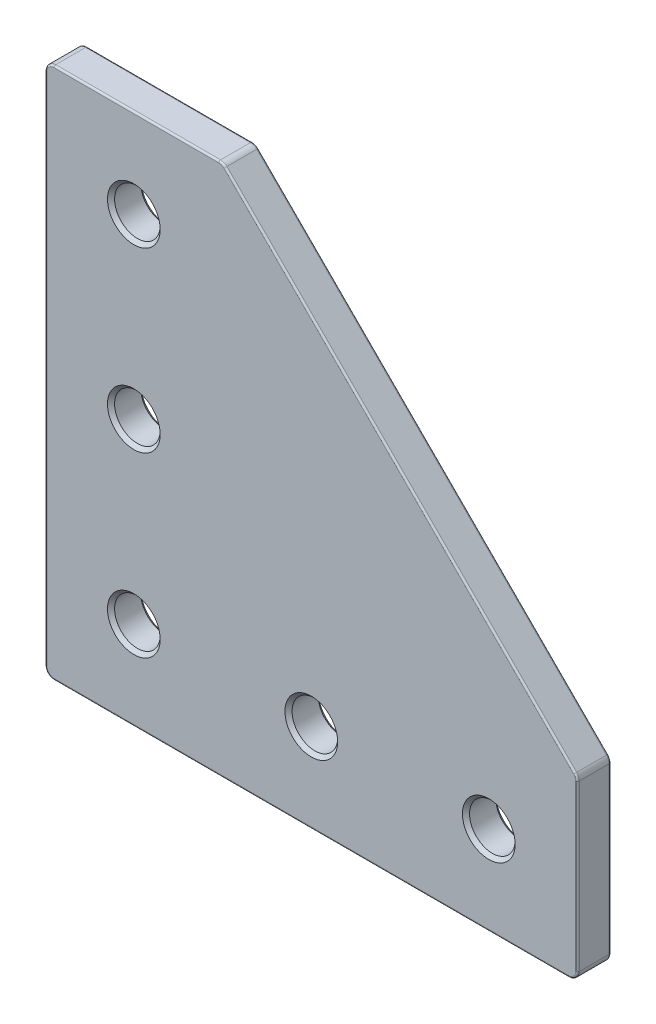
from build123d import *

# Parameters (mm, degrees)
BOSS_EXTRUDE1_START         = -2.3876
BOSS_EXTRUDE1_DEPTH         = 4.7752
SKETCH4_R                   = 3.2639
CUT_EXTRUDE1_DEPTH          = 55.092721646
LPATTERN1_COUNT             = 3
LPATTERN1_PITCH             = 25.4
CIRPATTERN1_COPY_1_SKETCH_R = 3.2639
CIRPATTERN1_COPY_1_DEPTH    = 55.092721646
CIRPATTERN1_COPY_2_SKETCH_R = 3.2639
CIRPATTERN1_COPY_2_DEPTH    = 55.092721646
CIRPATTERN1_COPY_7_SKETCH_R = 3.2639
CIRPATTERN1_COPY_7_DEPTH    = 55.092721646
FILLET1_R                   = 1.27
FILLET2_R                   = 0.254


with BuildPart() as part:
    # Sketch3 → Boss-Extrude1 (new body)
    with BuildSketch(Plane.XY.offset(BOSS_EXTRUDE1_START)):
        Polygon((-38.1, 38.1), (-38.1, -38.1), (38.1, -38.1), (38.1, -12.7), (-12.7, 38.1), align=None)
    extrude(amount=BOSS_EXTRUDE1_DEPTH)

    # Sketch4 → Cut-Extrude1 (cut, symmetric)
    with BuildSketch(Plane.XY.offset(2.3876)):
        with Locations((-25.4, -25.4)):
            Circle(SKETCH4_R)
    cut_extrude1 = extrude(amount=CUT_EXTRUDE1_DEPTH, both=True, mode=Mode.SUBTRACT)

    # Cut-Extrude2 cone 1 section (through the dimple's axis) → Cut-Extrude2 (revolve, cut)
    with BuildSketch(Plane(origin=(-25.4, -25.4, 2.3876), x_dir=(0, -1, 0), z_dir=(1, 0, 0))):
        Polygon((0, 0), (3.7719, 0), (0, 3.7719), align=None)
    cut_extrude2 = revolve(axis=Axis((-25.4, -25.4, 2.3876), (0, 0, -1)), mode=Mode.SUBTRACT)

    # Cut-Extrude3 cone 1 section (through the dimple's axis) → Cut-Extrude3 (revolve, cut)
    with BuildSketch(Plane(origin=(-25.4, -25.4, -2.3876), x_dir=(0, 1, 0), z_dir=(1, 0, 0))):
        Polygon((0, 0), (3.7719, 0), (0, 3.7719), align=None)
    cut_extrude3 = revolve(axis=Axis((-25.4, -25.4, -2.3876), (0, 0, 1)), mode=Mode.SUBTRACT)

    # LPattern1: Cut-Extrude1, Cut-Extrude2, Cut-Extrude3 ×3
    with Locations(*[(0, i * LPATTERN1_PITCH, 0) for i in range(1, LPATTERN1_COUNT)]):
        add(cut_extrude1, mode=Mode.SUBTRACT)
        add(cut_extrude2, mode=Mode.SUBTRACT)
        add(cut_extrude3, mode=Mode.SUBTRACT)

    # CirPattern1 copy 1 sketch → CirPattern1 copy 1 (cut, symmetric)
    with BuildSketch(Plane(origin=(25.4, -50.8, 2.3876), x_dir=(0, -1, 0), z_dir=(0, 0, 1))):
        with Locations((-25.4, -25.4)):
            Circle(CIRPATTERN1_COPY_1_SKETCH_R)
    extrude(amount=CIRPATTERN1_COPY_1_DEPTH, both=True, mode=Mode.SUBTRACT)

    # CirPattern1 copy 2 sketch → CirPattern1 copy 2 (cut, symmetric)
    with BuildSketch(Plane(origin=(50.8, -50.8, 2.3876), x_dir=(0, -1, 0), z_dir=(0, 0, 1))):
        with Locations((-25.4, -25.4)):
            Circle(CIRPATTERN1_COPY_2_SKETCH_R)
    extrude(amount=CIRPATTERN1_COPY_2_DEPTH, both=True, mode=Mode.SUBTRACT)

    # CirPattern1 copy 3 sketch → CirPattern1 copy 3 (revolve, cut)
    with BuildSketch(Plane(origin=(0, -25.4, 2.3876), x_dir=(-1, 0, 0), z_dir=(0, -1, 0))):
        Polygon((0, 0), (3.7719, 0), (0, 3.7719), align=None)
    revolve(axis=Axis((0, -25.4, 2.3876), (0, 0, -1)), mode=Mode.SUBTRACT)

    # CirPattern1 copy 4 sketch → CirPattern1 copy 4 (revolve, cut)
    with BuildSketch(Plane(origin=(25.4, -25.4, 2.3876), x_dir=(-1, 0, 0), z_dir=(0, -1, 0))):
        Polygon((0, 0), (3.7719, 0), (0, 3.7719), align=None)
    revolve(axis=Axis((25.4, -25.4, 2.3876), (0, 0, -1)), mode=Mode.SUBTRACT)

    # CirPattern1 copy 5 sketch → CirPattern1 copy 5 (revolve, cut)
    with BuildSketch(Plane(origin=(0, -25.4, -2.3876), x_dir=(1, 0, 0), z_dir=(0, -1, 0))):
        Polygon((0, 0), (3.7719, 0), (0, 3.7719), align=None)
    revolve(axis=Axis((0, -25.4, -2.3876), (0, 0, 1)), mode=Mode.SUBTRACT)

    # CirPattern1 copy 6 sketch → CirPattern1 copy 6 (revolve, cut)
    with BuildSketch(Plane(origin=(25.4, -25.4, -2.3876), x_dir=(1, 0, 0), z_dir=(0, -1, 0))):
        Polygon((0, 0), (3.7719, 0), (0, 3.7719), align=None)
    revolve(axis=Axis((25.4, -25.4, -2.3876), (0, 0, 1)), mode=Mode.SUBTRACT)

    # CirPattern1 copy 7 sketch → CirPattern1 copy 7 (cut, symmetric)
    with BuildSketch(Plane(origin=(0, -50.8, 2.3876), x_dir=(0, -1, 0), z_dir=(0, 0, 1))):
        with Locations((-25.4, -25.4)):
            Circle(CIRPATTERN1_COPY_7_SKETCH_R)
    extrude(amount=CIRPATTERN1_COPY_7_DEPTH, both=True, mode=Mode.SUBTRACT)

    # CirPattern1 copy 8 sketch → CirPattern1 copy 8 (revolve, cut)
    with BuildSketch(Plane(origin=(-25.4, -25.4, 2.3876), x_dir=(-1, 0, 0), z_dir=(0, -1, 0))):
        Polygon((0, 0), (3.7719, 0), (0, 3.7719), align=None)
    revolve(axis=Axis((-25.4, -25.4, 2.3876), (0, 0, -1)), mode=Mode.SUBTRACT)

    # CirPattern1 copy 9 sketch → CirPattern1 copy 9 (revolve, cut)
    with BuildSketch(Plane(origin=(-25.4, -25.4, -2.3876), x_dir=(1, 0, 0), z_dir=(0, -1, 0))):
        Polygon((0, 0), (3.7719, 0), (0, 3.7719), align=None)
    revolve(axis=Axis((-25.4, -25.4, -2.3876), (0, 0, 1)), mode=Mode.SUBTRACT)

    # Fillet1
    fillet1_edges = [part.edges().sort_by_distance(p)[0] for p in [
        (-12.7, 38.1, 0),
        (38.1, -12.7, 0),
        (38.1, -38.1, 0),
        (-38.1, -38.1, 0),
        (-38.1, 38.1, 0),
    ]]
    fillet(fillet1_edges, radius=FILLET1_R)

    # Fillet2
    fillet2_edges = [part.edges().sort_by_distance(p)[0] for p in [
        (12.7, 12.7, -2.3876),
        (12.7, 12.7, 2.3876),
        (-25.028025612, 38.1, -2.3876),
        (38.1, -25.028025612, -2.3876),
        (0, -38.1, -2.3876),
        (-38.1, 0, -2.3876),
        (-12.740043265, 38.003327006, -2.3876),
        (-37.728025612, 37.728025612, -2.3876),
        (-37.728025612, -37.728025612, -2.3876),
        (37.728025612, -37.728025612, -2.3876),
        (38.003327006, -12.740043265, -2.3876),
        (38.1, -25.028025612, 2.3876),
        (-25.028025612, 38.1, 2.3876),
        (-38.1, 0, 2.3876),
        (0, -38.1, 2.3876),
        (-12.740043265, 38.003327006, 2.3876),
        (-37.728025612, 37.728025612, 2.3876),
        (-37.728025612, -37.728025612, 2.3876),
        (37.728025612, -37.728025612, 2.3876),
        (38.003327006, -12.740043265, 2.3876),
    ]]
    fillet(fillet2_edges, radius=FILLET2_R)


solid = part.part
